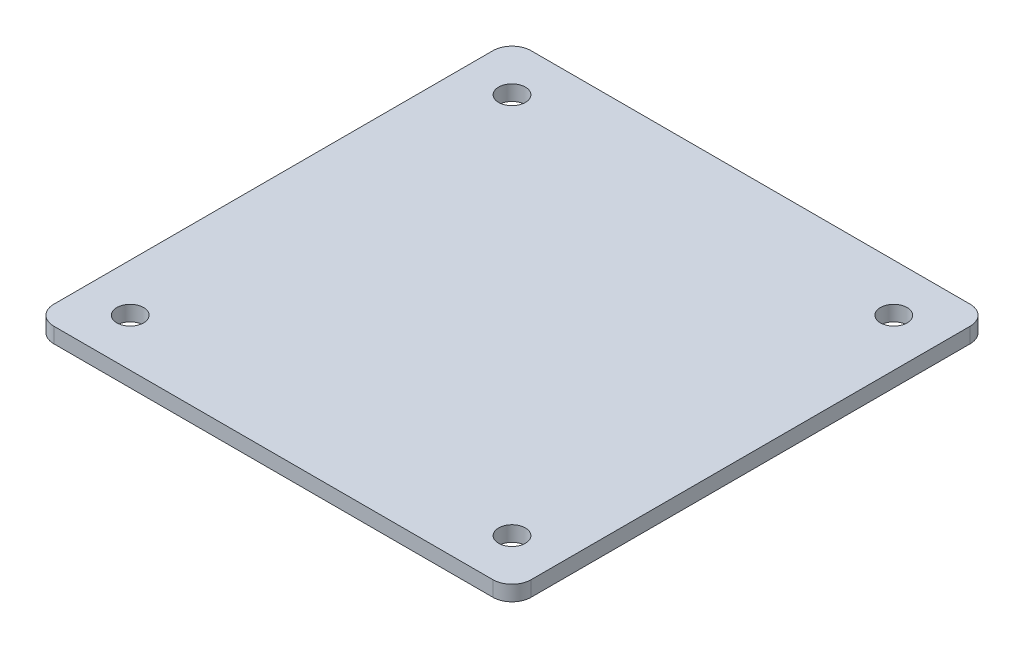
from build123d import *

# Parameters (mm, degrees)
ESQUISSE1_R        = 7
BOSS_EXTRU_1_DEPTH = 8


with BuildPart() as part:
    # Esquisse1 → Boss.-Extru.1 (new body)
    with BuildSketch(Plane(origin=(0, 0, 0), x_dir=(1, 0, 0), z_dir=(0, 1, 0))):
        with BuildLine():
            Line((10, 0), (240, 0))
            ThreePointArc((240, 0), (247.071067812, 2.928932188), (250, 10))
            Line((250, 10), (250, 240))
            ThreePointArc((250, 240), (247.071067812, 247.071067812), (240, 250))
            Line((240, 250), (10, 250))
            ThreePointArc((10, 250), (2.928932188, 247.071067812), (0, 240))
            Line((0, 240), (0, 10))
            ThreePointArc((0, 10), (2.928932188, 2.928932188), (10, 0))
        make_face()
        with Locations(Location((25, 225, 0), (0, 0, 270))):  # turned: the seam where the file's is
            Circle(ESQUISSE1_R, mode=Mode.SUBTRACT)
        with Locations(Location((225, 225, 0), (0, 0, 270))):  # turned: the seam where the file's is
            Circle(ESQUISSE1_R, mode=Mode.SUBTRACT)
        with Locations(Location((225, 25, 0), (0, 0, 270))):  # turned: the seam where the file's is
            Circle(ESQUISSE1_R, mode=Mode.SUBTRACT)
        with Locations(Location((25, 25, 0), (0, 0, 270))):  # turned: the seam where the file's is
            Circle(ESQUISSE1_R, mode=Mode.SUBTRACT)
    extrude(amount=BOSS_EXTRU_1_DEPTH)


solid = part.part
